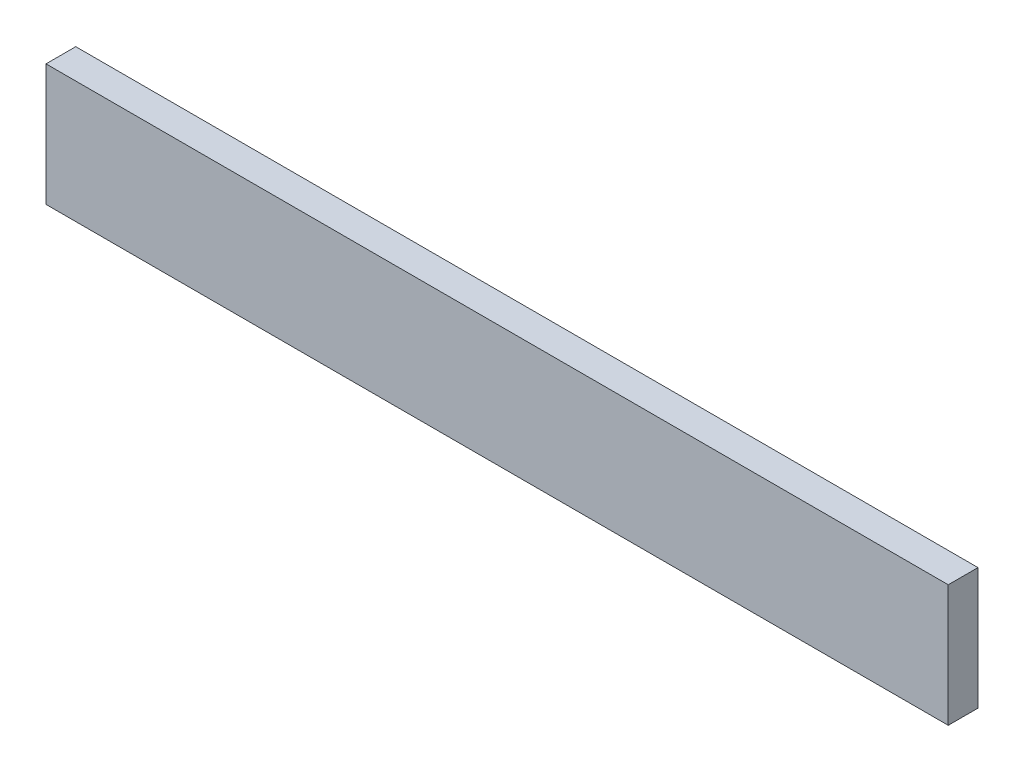
from build123d import *

# Parameters (mm, degrees)
ESQUISSE1_W      = 667
ESQUISSE1_H      = 90
EXTRUSION1_DEPTH = 22


with BuildPart() as part:
    # Esquisse1 → Extrusion1 (new body)
    with BuildSketch(Plane.XY):
        with Locations((333.5, 45)):
            Rectangle(ESQUISSE1_W, ESQUISSE1_H)
    extrude(amount=EXTRUSION1_DEPTH)


solid = part.part
